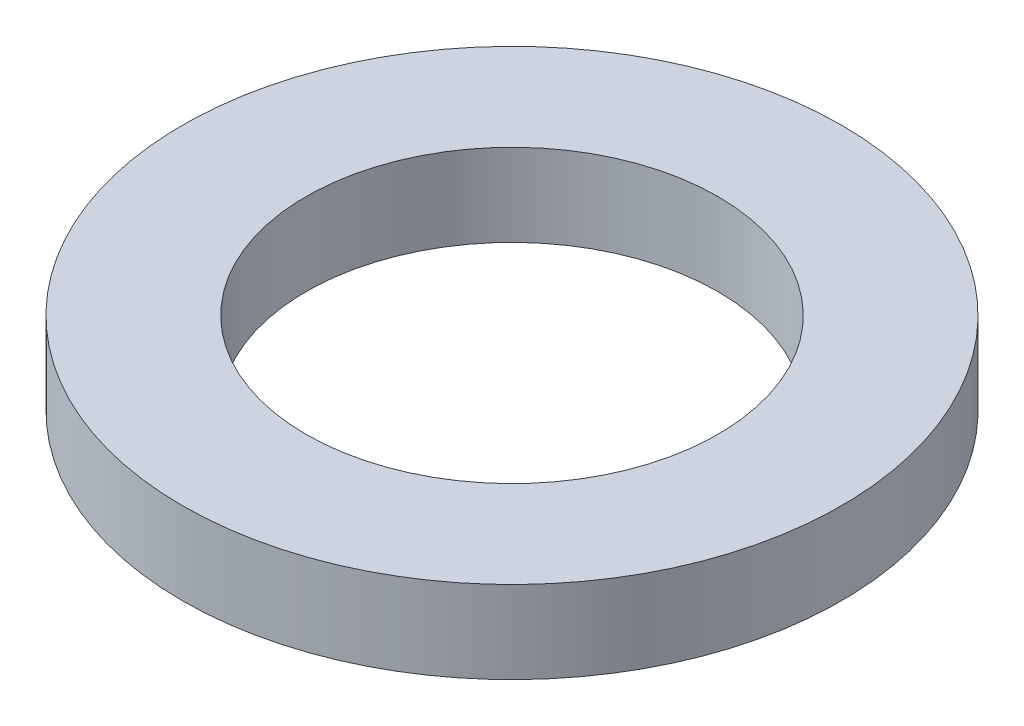
from build123d import *

# Parameters (mm, degrees)
SKETCH1_R           = 4
SKETCH1_R_2         = 2.5
BOSS_EXTRUDE1_DEPTH = 1


with BuildPart() as part:
    # Sketch1 → Boss-Extrude1 (new body)
    with BuildSketch(Plane(origin=(0, 0, 0), x_dir=(1, 0, 0), z_dir=(0, 1, 0))):
        Circle(SKETCH1_R)
        Circle(SKETCH1_R_2, mode=Mode.SUBTRACT)
    extrude(amount=BOSS_EXTRUDE1_DEPTH)


solid = part.part
